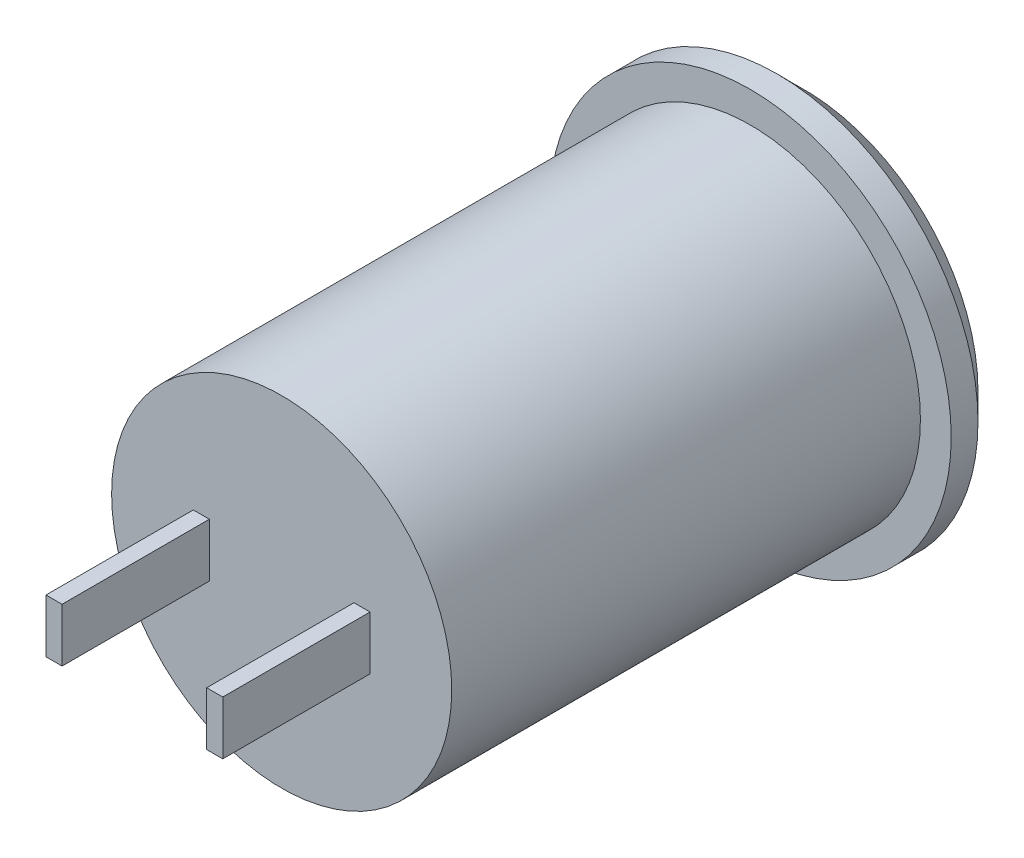
from build123d import *

# Parameters (mm, degrees)
F_3_8_0_375_DIAMETER_HOLE1_D     = 9.525
F_3_8_0_375_DIAMETER_HOLE1_DEPTH = 5.999988
F_3_8_0_375_DIAMETER_HOLE1_TIP   = 2.861598698
SKETCH6_W                        = 0.6
SKETCH6_H                        = 2
BOSS_EXTRUDE1_DEPTH              = 5.5


with BuildPart() as part:
    # Sketch1 → Revolve2 (revolve)
    with BuildSketch(Plane(origin=(0, 0, 0), x_dir=(1, 0, 0), z_dir=(0, 1, 0))):
        Polygon((0, 0), (6.35, 0), (6.35, 17.5), (7.5, 17.5), (7.5, 18.5), (6.5, 19.5), (0, 19.5), align=None)
    revolve(axis=Axis((0, 0, -19.5), (0, 0, 1)))

    # 3/8 (0.375) Diameter Hole1
    with Locations(Plane(origin=(0, 0, -19.5), x_dir=(-1, 0, 0), z_dir=(0, 0, -1))):
        with Locations((0, 0)):
            Hole(F_3_8_0_375_DIAMETER_HOLE1_D / 2, depth=F_3_8_0_375_DIAMETER_HOLE1_DEPTH)
            with Locations((0, 0, -(F_3_8_0_375_DIAMETER_HOLE1_DEPTH + F_3_8_0_375_DIAMETER_HOLE1_TIP / 2))):  # 118° drill point
                Cone(0, F_3_8_0_375_DIAMETER_HOLE1_D / 2, F_3_8_0_375_DIAMETER_HOLE1_TIP, mode=Mode.SUBTRACT)

    # Sketch6 → Boss-Extrude1 (add)
    with BuildSketch(Plane.XY):
        with Locations((-3, 0)):
            Rectangle(SKETCH6_W, SKETCH6_H)
    boss_extrude1 = extrude(amount=BOSS_EXTRUDE1_DEPTH)

    # Mirror1: Boss-Extrude1 across plane
    add(boss_extrude1.mirror(Plane(origin=(0, 0, 0), x_dir=(0, 0, 1), z_dir=(1, 0, 0))))


solid = part.part
